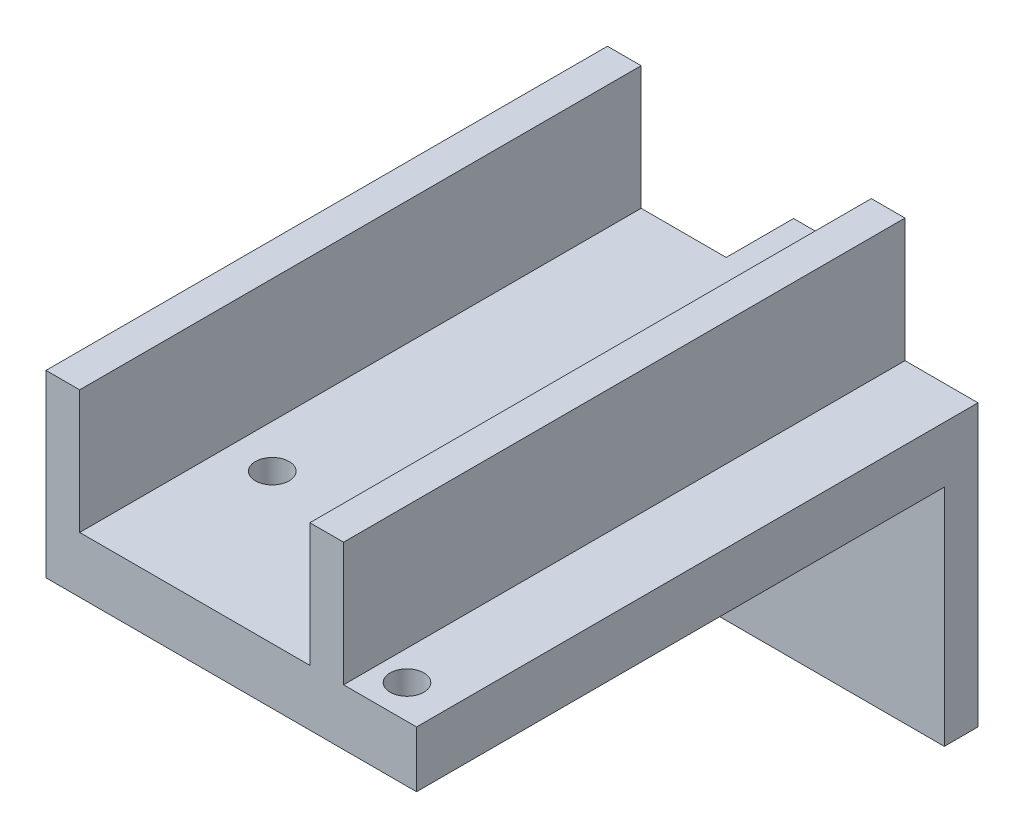
from build123d import *

# Parameters (mm, degrees)
SKETCH_1_W               = 30
SKETCH_1_H               = 50
EXTRUDE_1_DEPTH          = 5
SKETCH_2_R               = 1.5
CUT_EXTRUDE_2_DEPTH      = 6
CUT_EXTRUDE_2_DEPTH_BACK = 3
SKETCH_3_W               = 30
SKETCH_3_H               = 25
EXTRUDE_2_DEPTH          = 3
SKETCH_4_W               = 4.85
SKETCH_4_H               = 20
EXTRUDE_3_DEPTH          = 6
EXTRUDE_START            = -50
SKETCH_6_W               = 3
SKETCH_6_H               = 16
EXTRUDE_4_DEPTH          = 50


with BuildPart() as part:
    # 스케치1 → 보스-돌출1 (new body)
    with BuildSketch(Plane(origin=(0, 0, 0), x_dir=(1, 0, 0), z_dir=(0, 1, 0))):
        Rectangle(SKETCH_1_W, SKETCH_1_H)
    extrude(amount=EXTRUDE_1_DEPTH)

    # 스케치2 → 컷-돌출2 (cut, two sides)
    with BuildSketch(Plane(origin=(0, 0, 0), x_dir=(1, 0, 0), z_dir=(0, 1, 0))) as cut_extrude_2_sk:
        with Locations((-11.15, -11.7)):
            Circle(SKETCH_2_R)
        with Locations((11.15, -22)):
            Circle(SKETCH_2_R)
    extrude(amount=CUT_EXTRUDE_2_DEPTH, mode=Mode.SUBTRACT)
    extrude(cut_extrude_2_sk.sketch, amount=-CUT_EXTRUDE_2_DEPTH_BACK, mode=Mode.SUBTRACT)

    # 스케치3 → 보스-돌출2 (add)
    with BuildSketch(Plane(origin=(0, 0, -25), x_dir=(-1, 0, 0), z_dir=(0, 0, -1))):
        with Locations((0, -7.5)):
            Rectangle(SKETCH_3_W, SKETCH_3_H)
    extrude(amount=-EXTRUDE_2_DEPTH)

    # 스케치4 → 보스-돌출3 (add)
    with BuildSketch(Plane(origin=(0, 0, -25), x_dir=(-1, 0, 0), z_dir=(0, 0, -1))):
        with Locations((5, -5)):
            Rectangle(SKETCH_4_W, SKETCH_4_H)
    extrude(amount=EXTRUDE_3_DEPTH)

    # 스케치6 → 보스-돌출4 (add)
    with BuildSketch(Plane.XY.offset(25).offset(EXTRUDE_START)):
        with Locations((-16.5, 8)):
            Rectangle(SKETCH_6_W, SKETCH_6_H)
        with Locations((7, 8)):
            Rectangle(SKETCH_6_W, SKETCH_6_H)
    extrude(amount=EXTRUDE_4_DEPTH)


solid = part.part
